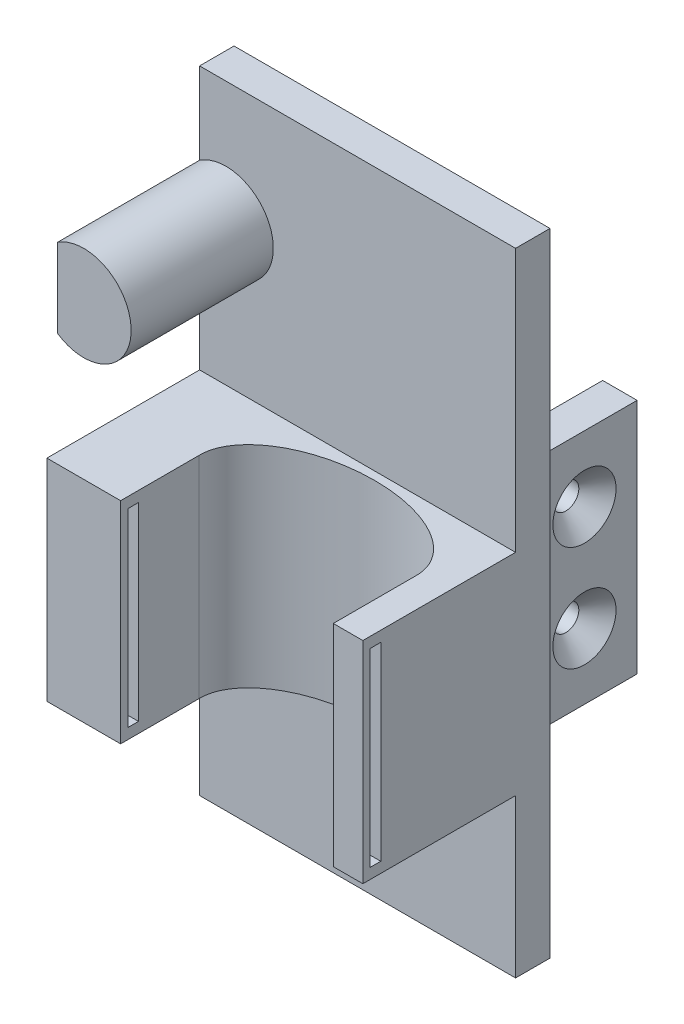
from build123d import *

# Parameters (mm, degrees)
SKETCH1_W                                       = 60
SKETCH1_H                                       = 120
BOSS_EXTRUDE1_DEPTH                             = 6.54
BOSS_EXTRUDE4_DEPTH                             = 27
SKETCH10_W                                      = 6.54
SKETCH10_H                                      = 45
BOSS_EXTRUDE5_DEPTH                             = 20
SKETCH17_W                                      = 60
SKETCH17_H                                      = 40
BOSS_EXTRUDE6_DEPTH                             = 29
CUT_EXTRUDE1_REACH                              = 72
SKETCH18_RX                                     = 20.2
SKETCH18_RY                                     = 12
CUT_EXTRUDE2_REACH                              = 57.54
SKETCH21_W                                      = 40.3853088
SKETCH21_H                                      = 40
SKETCH23_W                                      = 2
SKETCH23_H                                      = 36
CUT_EXTRUDE3_DEPTH                              = 9
SKETCH24_W                                      = 2
SKETCH24_H                                      = 36
CUT_EXTRUDE4_DEPTH                              = 9
CSK_FOR_M3_FLAT_HEAD_MACHINE_SCREW4_D           = 4.93
CSK_FOR_M3_FLAT_HEAD_MACHINE_SCREW4_DEPTH       = 6.54
CSK_FOR_M3_FLAT_HEAD_MACHINE_SCREW4_CSINK_D     = 12
CSK_FOR_M3_FLAT_HEAD_MACHINE_SCREW4_CSINK_ANGLE = 90
CSK_FOR_M3_FLAT_HEAD_MACHINE_SCREW5_D           = 4.93
CSK_FOR_M3_FLAT_HEAD_MACHINE_SCREW5_DEPTH       = 6.54
CSK_FOR_M3_FLAT_HEAD_MACHINE_SCREW5_CSINK_D     = 12
CSK_FOR_M3_FLAT_HEAD_MACHINE_SCREW5_CSINK_ANGLE = 90


with BuildPart() as part:
    # Sketch1 → Boss-Extrude1 (new body)
    with BuildSketch(Plane.XY):
        Rectangle(SKETCH1_W, SKETCH1_H)
    extrude(amount=BOSS_EXTRUDE1_DEPTH)

    # Sketch7 → Boss-Extrude4 (add)
    with BuildSketch(Plane.XY.offset(6.54)):
        with BuildLine():
            Line((-30, 44.483314774), (-30, 29.516685226))
            ThreePointArc((-30, 29.516685226), (-16, 37), (-30, 44.483314774))
        make_face()
    extrude(amount=BOSS_EXTRUDE4_DEPTH)

    # Sketch10 → Boss-Extrude5 (add)
    with BuildSketch(Plane(origin=(0, 0, 0), x_dir=(-1, 0, 0), z_dir=(0, 0, -1))):
        with Locations((23.27, -2.5)):
            Rectangle(SKETCH10_W, SKETCH10_H)
        with Locations((-23.27, -2.5)):
            Rectangle(SKETCH10_W, SKETCH10_H)
    extrude(amount=BOSS_EXTRUDE5_DEPTH)

    # Sketch17 → Boss-Extrude6 (add)
    with BuildSketch(Plane.XY.offset(6.54)):
        with Locations((0, -10)):
            Rectangle(SKETCH17_W, SKETCH17_H)
    extrude(amount=BOSS_EXTRUDE6_DEPTH)

    # Sketch18 → Cut-Extrude1 (cut, up to next)
    with BuildSketch(Plane(origin=(0, 10, 0), x_dir=(1, 0, 0), z_dir=(0, 1, 0)), mode=Mode.PRIVATE) as cut_extrude1_sk1:
        with Locations(Location((4.192654401, -20.096314851), (0, 0, 1.545214336))):
            Ellipse(SKETCH18_RX, SKETCH18_RY)
    cut_extrude1_tool1 = extrude(cut_extrude1_sk1.sketch, amount=-CUT_EXTRUDE1_REACH, mode=Mode.PRIVATE) & part.part
    add(cut_extrude1_tool1.solids().sort_by_distance((4.192654, 10, 20.096315))[0], mode=Mode.SUBTRACT)

    # Sketch21 → Cut-Extrude2 (cut, up to next)
    with BuildSketch(Plane.XY.offset(35.54), mode=Mode.PRIVATE) as cut_extrude2_sk1:
        with Locations((4.1926544, -10)):
            Rectangle(SKETCH21_W, SKETCH21_H)
    cut_extrude2_tool1 = extrude(cut_extrude2_sk1.sketch, amount=-CUT_EXTRUDE2_REACH, mode=Mode.PRIVATE) & part.part
    add(cut_extrude2_tool1.solids().sort_by_distance((4.192654, -10, 35.54))[0], mode=Mode.SUBTRACT)

    # Sketch23 → Cut-Extrude3 (cut)
    with BuildSketch(Plane(origin=(-16, 0, 0), x_dir=(0, 0, -1), z_dir=(1, 0, 0))):
        with Locations((-33.14, -10)):
            Rectangle(SKETCH23_W, SKETCH23_H)
    extrude(amount=-CUT_EXTRUDE3_DEPTH, mode=Mode.SUBTRACT)

    # Sketch24 → Cut-Extrude4 (cut)
    with BuildSketch(Plane.ZY.offset(-24.3853088)):
        with Locations((33.14, -10)):
            Rectangle(SKETCH24_W, SKETCH24_H)
    extrude(amount=-CUT_EXTRUDE4_DEPTH, mode=Mode.SUBTRACT)

    # CSK for M3 Flat Head Machine Screw4
    with Locations(Plane(origin=(26.54, -12.5, -10), x_dir=(0, 1, 0), z_dir=(1, 0, 0))):
        with Locations((0, 0), (20, 0)):
            CounterSinkHole(CSK_FOR_M3_FLAT_HEAD_MACHINE_SCREW4_D / 2, CSK_FOR_M3_FLAT_HEAD_MACHINE_SCREW4_CSINK_D / 2, depth=CSK_FOR_M3_FLAT_HEAD_MACHINE_SCREW4_DEPTH, counter_sink_angle=CSK_FOR_M3_FLAT_HEAD_MACHINE_SCREW4_CSINK_ANGLE)

    # CSK for M3 Flat Head Machine Screw5
    with Locations(Plane(origin=(-26.54, -12.5, -10), x_dir=(0, -1, 0), z_dir=(-1, 0, 0))):
        with Locations((0, 0), (-20, 0)):
            CounterSinkHole(CSK_FOR_M3_FLAT_HEAD_MACHINE_SCREW5_D / 2, CSK_FOR_M3_FLAT_HEAD_MACHINE_SCREW5_CSINK_D / 2, depth=CSK_FOR_M3_FLAT_HEAD_MACHINE_SCREW5_DEPTH, counter_sink_angle=CSK_FOR_M3_FLAT_HEAD_MACHINE_SCREW5_CSINK_ANGLE)


solid = part.part
